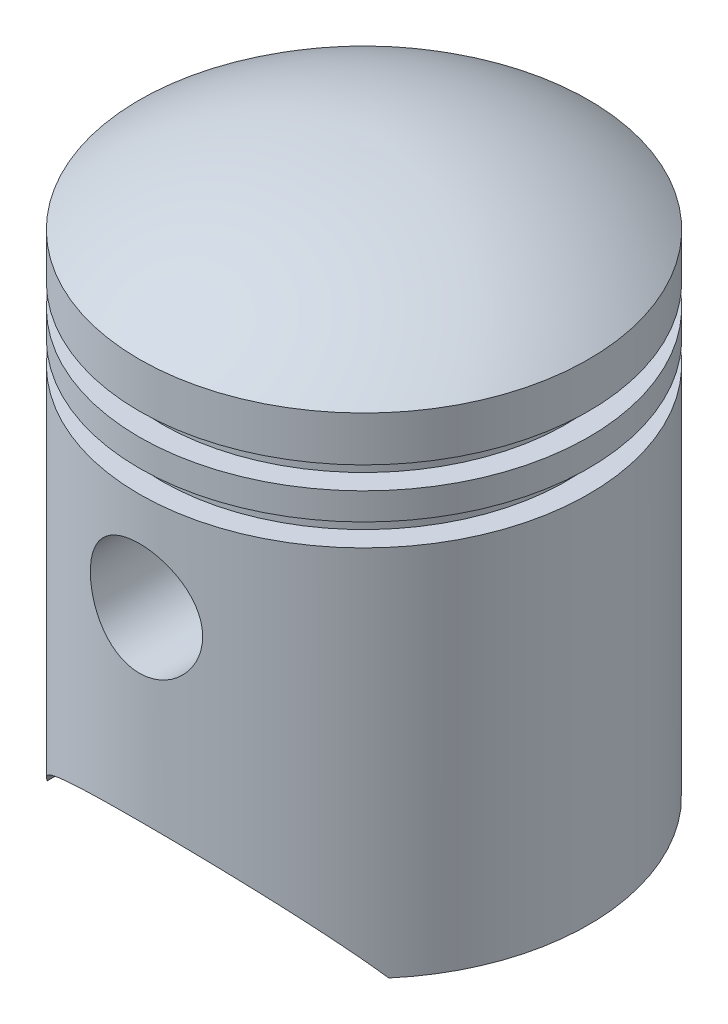
from build123d import *

# Parameters (mm, degrees)
SKETCH2_R               = 158.75
CUT_EXTRUDE1_DEPTH      = 636.0000001
CUT_EXTRUDE1_DEPTH_BACK = 636.0000001
BOSS_EXTRUDE1_START     = 304.8
SKETCH3_R               = 184.15
SKETCH3_R_2             = 158.75
BOSS_EXTRUDE1_DEPTH     = 302.91192


with BuildPart() as part:
    # Sketch1 → Revolve1 (revolve)
    with BuildSketch(Plane.XY):
        with BuildLine():
            Line((635, 0), (635, 1054.1))
            Line((635, 1054.1), (571.5, 1054.1))
            Line((571.5, 1054.1), (571.5, 1117.6))
            Line((571.5, 1117.6), (635, 1117.6))
            Line((635, 1117.6), (635, 1193.8))
            Line((635, 1193.8), (571.5, 1193.8))
            Line((571.5, 1193.8), (571.5, 1257.3))
            Line((571.5, 1257.3), (635, 1257.3))
            Line((635, 1257.3), (635, 1384.3))
            ThreePointArc((635, 1384.3), (334.642502957, 1539.470321739), (0, 1587.5))
            Line((0, 1587.5), (0, 1536.683816385))
            ThreePointArc((0, 1536.683816385), (306.565112988, 1495.022802298), (584.2, 1358.506583081))
            Line((584.2, 1358.506583081), (584.2, 1308.1))
            Line((584.2, 1308.1), (520.7, 1308.1))
            Line((520.7, 1308.1), (520.7, 1155.7))
            Line((520.7, 1155.7), (520.7, 1003.3))
            Line((520.7, 1003.3), (584.2, 1003.3))
            Line((584.2, 1003.3), (584.2, 0))
            Line((584.2, 0), (635, 0))
        make_face()
    revolve(axis=Axis((0, 1587.5, 0), (0, -1, 0)))

    # Sketch2 → Cut-Extrude1 (cut, two sides)
    with BuildSketch(Plane.XY) as cut_extrude1_sk:
        with Locations((0, 774.7)):
            Circle(SKETCH2_R)
        with BuildLine():
            Line((-482.6, 0), (482.6, 0))
            ThreePointArc((482.6, 0), (0, 254), (-482.6, 0))
        make_face()
    extrude(amount=CUT_EXTRUDE1_DEPTH, mode=Mode.SUBTRACT)
    extrude(cut_extrude1_sk.sketch, amount=-CUT_EXTRUDE1_DEPTH_BACK, mode=Mode.SUBTRACT)

    # Sketch3 → Boss-Extrude1 (add)
    with BuildSketch(Plane.XY.offset(BOSS_EXTRUDE1_START)):
        with Locations((0, 774.7)):
            Circle(SKETCH3_R)
        with Locations((0, 774.7)):
            Circle(SKETCH3_R_2, mode=Mode.SUBTRACT)
    boss_extrude1 = extrude(amount=BOSS_EXTRUDE1_DEPTH)

    # Mirror1: Boss-Extrude1 across plane
    add(boss_extrude1.mirror(Plane.XY))


solid = part.part
